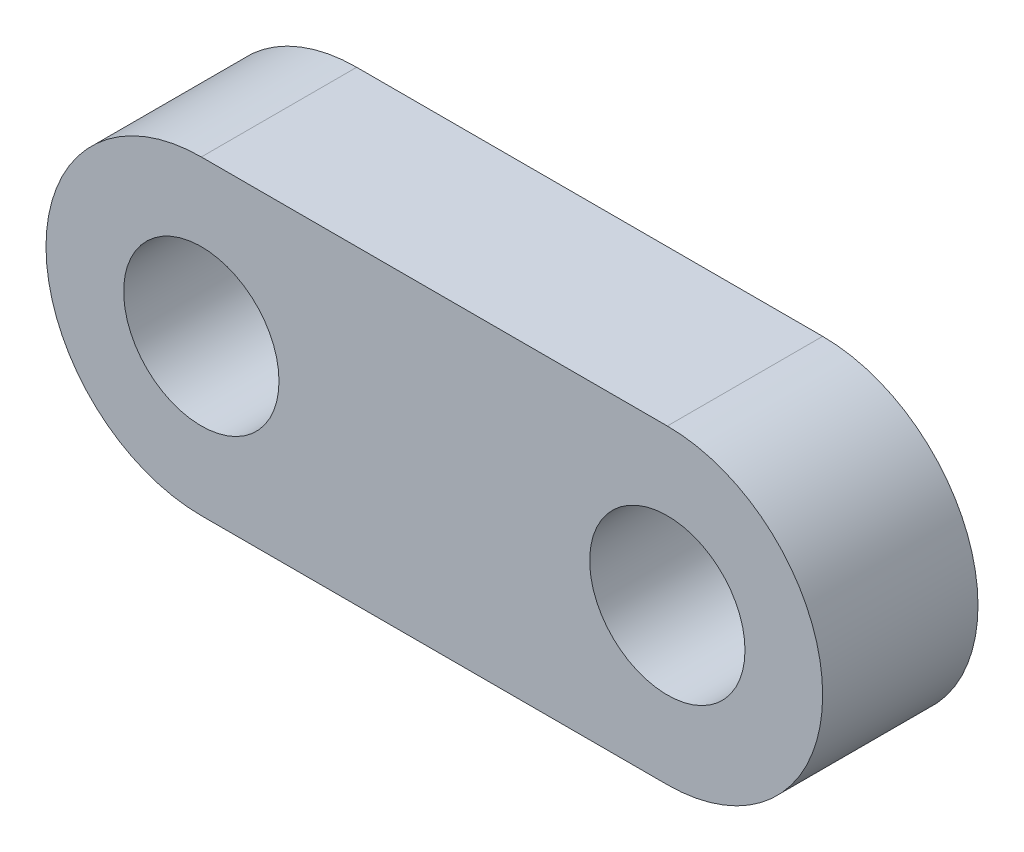
from build123d import *

# Parameters (mm, degrees)
SKETCH1_R           = 3.175
EXTRUSION2_DEPTH    = 6.35
SKETCH1_3_R         = 6.35
BOSS_EXTRUDE1_DEPTH = 6.35
SKETCH1_4_R         = 3.175
CUT_EXTRUDE1_DEPTH  = 6.35


with BuildPart() as part:
    # Sketch1 → Extrusion2 (new body)
    with BuildSketch(Plane.XY):
        with BuildLine():
            Line((0, 0), (19.05, 0))
            ThreePointArc((19.05, 0), (12.7, 6.35), (19.05, 12.7))
            Line((19.05, 12.7), (0, 12.7))
            ThreePointArc((0, 12.7), (-6.35, 6.35), (0, 0))
        make_face()
        with Locations((0, 6.35)):
            Circle(SKETCH1_R, mode=Mode.SUBTRACT)
    extrude(amount=EXTRUSION2_DEPTH)

    # Sketch1_3 → Boss-Extrude1 (add)
    with BuildSketch(Plane.XY):
        with Locations((19.05, 6.35)):
            Circle(SKETCH1_3_R)
    extrude(amount=BOSS_EXTRUDE1_DEPTH)

    # Sketch1_4 → Cut-Extrude1 (cut)
    with BuildSketch(Plane.XY):
        with Locations((19.05, 6.35)):
            Circle(SKETCH1_4_R)
    extrude(amount=CUT_EXTRUDE1_DEPTH, mode=Mode.SUBTRACT)


solid = part.part
